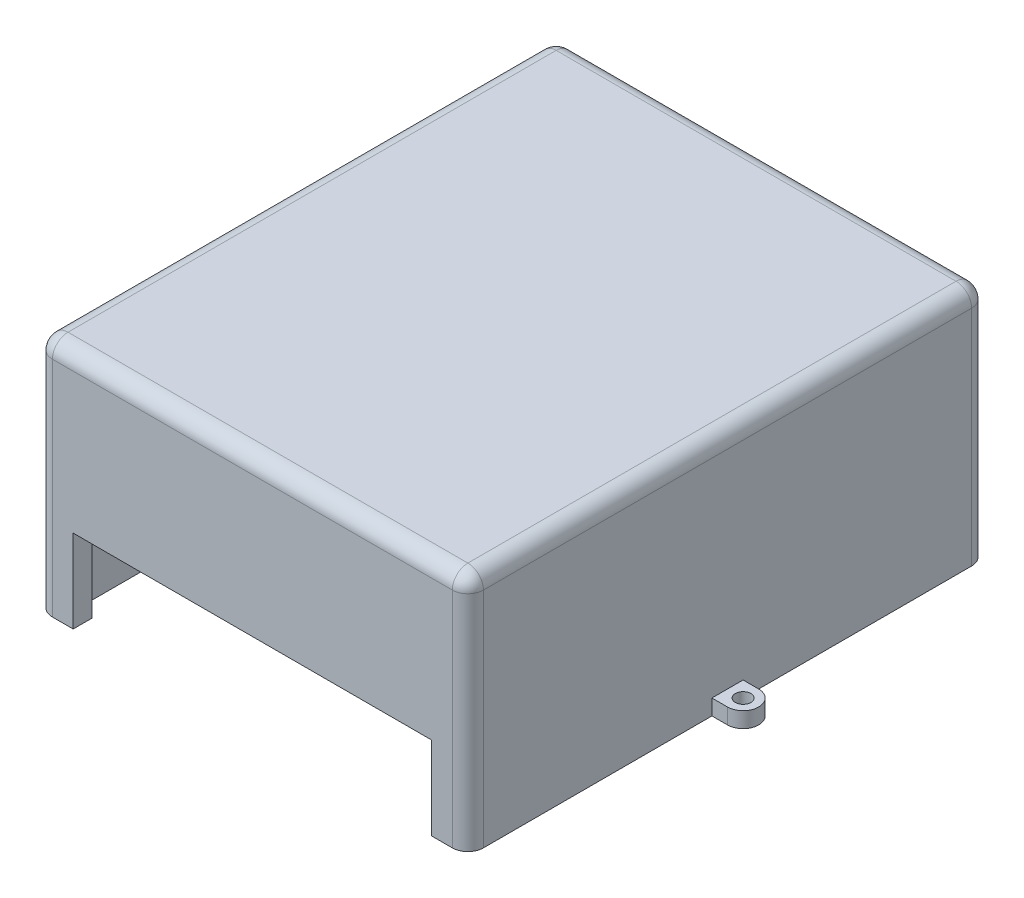
from build123d import *

# Parameters (mm, degrees)
CROQUIS2_W              = 83
CROQUIS2_H              = 100
CROQUIS2_W_2            = 76
CROQUIS2_H_2            = 93.334161502
SALIENTE_EXTRUIR1_DEPTH = 43
CROQUIS3_W              = 83
CROQUIS3_H              = 3
SALIENTE_EXTRUIR2_DEPTH = 100
CROQUIS4_W              = 69
CROQUIS4_H              = 16
CORTAR_EXTRUIR3_DEPTH   = 10
SALIENTE_EXTRUIR3_DEPTH = 3
CROQUIS6_R              = 1.5
CORTAR_EXTRUIR4_DEPTH   = 13
REDONDEO1_R             = 3
REDONDEO2_R             = 1


with BuildPart() as part:
    # Croquis2 → Saliente-Extruir1 (new body)
    with BuildSketch(Plane(origin=(0, -3.101295798, 0), x_dir=(1, 0, 0), z_dir=(0, 1, 0))):
        with Locations((-13.660303869, -172.250641144)):
            Rectangle(CROQUIS2_W, CROQUIS2_H)
        with Locations((-13.160303869, -171.917721895)):
            Rectangle(CROQUIS2_W_2, CROQUIS2_H_2, mode=Mode.SUBTRACT)
    extrude(amount=SALIENTE_EXTRUIR1_DEPTH)

    # Croquis3 → Saliente-Extruir2 (add)
    with BuildSketch(Plane.XY.offset(222.250641144)):
        with Locations((-13.660303869, 41.398704202)):
            Rectangle(CROQUIS3_W, CROQUIS3_H)
    extrude(amount=-SALIENTE_EXTRUIR2_DEPTH)

    # Croquis4 → Cortar-Extruir3 (cut)
    with BuildSketch(Plane.XY.offset(222.250641144)):
        with Locations((-13.660303869, 4.898704202)):
            Rectangle(CROQUIS4_W, CROQUIS4_H)
    extrude(amount=-CORTAR_EXTRUIR3_DEPTH, mode=Mode.SUBTRACT)

    # Croquis5 → Saliente-Extruir3 (add)
    with BuildSketch(Plane(origin=(0, -3.101295798, 0), x_dir=(1, 0, 0), z_dir=(0, 1, 0))):
        with BuildLine():
            Line((-58.160303869, -169.250641144), (-55.160303869, -169.250641144))
            Line((-55.160303869, -169.250641144), (-55.160303869, -175.250641144))
            Line((-55.160303869, -175.250641144), (-58.160303869, -175.250641144))
            ThreePointArc((-58.160303869, -175.250641144), (-61.160303869, -172.250641144), (-58.160303869, -169.250641144))
        make_face()
        with BuildLine():
            Line((-16.660303869, -119.250641144), (-16.660303869, -122.250641144))
            Line((-16.660303869, -122.250641144), (-10.660303869, -122.250641144))
            Line((-10.660303869, -122.250641144), (-10.660303869, -119.250641144))
            ThreePointArc((-10.660303869, -119.250641144), (-13.660303869, -116.250641144), (-16.660303869, -119.250641144))
        make_face()
        with BuildLine():
            Line((30.839696131, -169.250641144), (27.839696131, -169.250641144))
            Line((27.839696131, -169.250641144), (27.839696131, -175.250641144))
            Line((27.839696131, -175.250641144), (30.839696131, -175.250641144))
            ThreePointArc((30.839696131, -175.250641144), (33.839696131, -172.250641144), (30.839696131, -169.250641144))
        make_face()
    extrude(amount=SALIENTE_EXTRUIR3_DEPTH)

    # Croquis6 → Cortar-Extruir4 (cut)
    with BuildSketch(Plane(origin=(0, -0.101295798, 0), x_dir=(1, 0, 0), z_dir=(0, 1, 0))):
        with Locations((30.839696131, -172.250641144)):
            Circle(CROQUIS6_R)
        with Locations((-13.660303869, -119.250641144)):
            Circle(CROQUIS6_R)
        with Locations((-58.160303869, -172.250641144)):
            Circle(CROQUIS6_R)
    extrude(amount=-CORTAR_EXTRUIR4_DEPTH, mode=Mode.SUBTRACT)

    # Redondeo1
    redondeo1_edges = [part.edges().sort_by_distance(p)[0] for p in [
        (-13.660303869, 42.898704202, 122.250641144),
        (-55.160303869, 42.898704202, 172.250641144),
        (27.839696131, 42.898704202, 172.250641144),
        (-13.660303869, 42.898704202, 222.250641144),
        (-55.160303869, 19.898704202, 122.250641144),
        (27.839696131, 19.898704202, 122.250641144),
        (27.839696131, 19.898704202, 222.250641144),
        (-55.160303869, 19.898704202, 222.250641144),
    ]]
    fillet(redondeo1_edges, radius=REDONDEO1_R)

    # Redondeo2
    redondeo2_edges = [part.edges().sort_by_distance(p)[0] for p in [
        (24.839696131, 18.398704202, 218.584802646),
        (24.839696131, 18.398704202, 125.250641144),
        (-51.160303869, 18.398704202, 125.250641144),
        (-51.160303869, 18.398704202, 218.584802646),
        (24.839696131, 39.898704202, 171.917721895),
        (-13.160303869, 39.898704202, 125.250641144),
        (-51.160303869, 39.898704202, 171.917721895),
        (-13.160303869, 39.898704202, 218.584802646),
    ]]
    fillet(redondeo2_edges, radius=REDONDEO2_R)


solid = part.part
